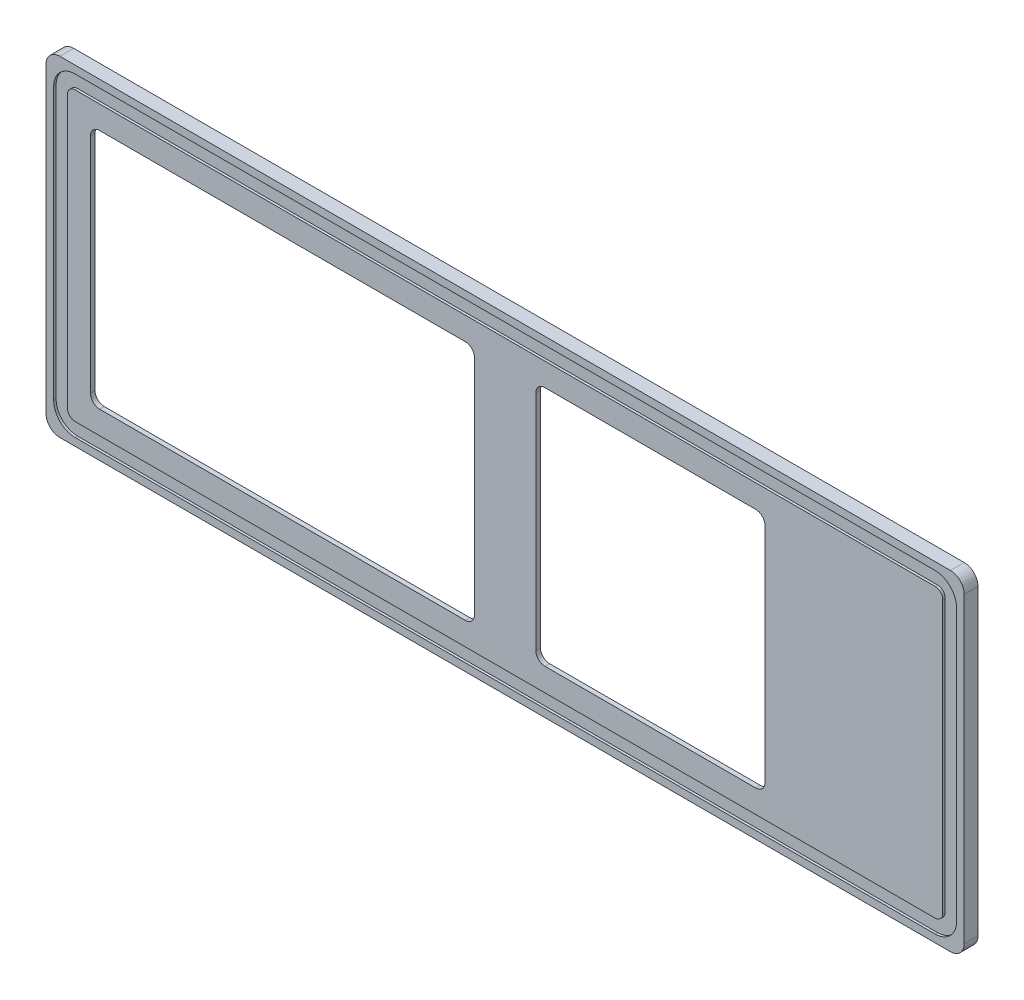
from build123d import *

# Parameters (mm, degrees)
BOSS_EXTRUDE1_DEPTH = 9
CUT_EXTRUDE1_DEPTH  = 1.6
CUT_EXTRUDE2_DEPTH  = 9
CUT_EXTRUDE4_DEPTH  = 6


with BuildPart() as part:
    # Sketch1 → Boss-Extrude1 (new body)
    with BuildSketch(Plane.XY):
        with BuildLine():
            Line((-290.5, 206.4), (290.5, 206.4))
            ThreePointArc((290.5, 206.4), (296.863961031, 203.763961031), (299.5, 197.4))
            Line((299.5, 197.4), (299.5, 0))
            ThreePointArc((299.5, 0), (296.863961031, -6.363961031), (290.5, -9))
            Line((290.5, -9), (-290.5, -9))
            ThreePointArc((-290.5, -9), (-296.863961031, -6.363961031), (-299.5, 0))
            Line((-299.5, 0), (-299.5, 197.4))
            ThreePointArc((-299.5, 197.4), (-296.863961031, 203.763961031), (-290.5, 206.4))
        make_face()
    extrude(amount=BOSS_EXTRUDE1_DEPTH)

    # Sketch4 → Cut-Extrude1 (cut)
    with BuildSketch(Plane.XY.offset(9)):
        with BuildLine():
            Line((-280.5, -4), (280.5, -4))
            ThreePointArc((280.5, -4), (290.399494937, 0.100505063), (294.5, 10))
            Line((294.5, 10), (294.5, 187.4))
            ThreePointArc((294.5, 187.4), (290.399494937, 197.299494937), (280.5, 201.4))
            Line((280.5, 201.4), (-280.5, 201.4))
            ThreePointArc((-280.5, 201.4), (-290.399494937, 197.299494937), (-294.5, 187.4))
            Line((-294.5, 187.4), (-294.5, 10))
            ThreePointArc((-294.5, 10), (-290.399494937, 0.100505063), (-280.5, -4))
        make_face()
        with BuildLine():
            Line((-280.5, 5), (280.5, 5))
            ThreePointArc((280.5, 5), (284.035533906, 6.464466094), (285.5, 10))
            Line((285.5, 10), (285.5, 187.4))
            ThreePointArc((285.5, 187.4), (284.035533906, 190.935533906), (280.5, 192.4))
            Line((280.5, 192.4), (-280.5, 192.4))
            ThreePointArc((-280.5, 192.4), (-284.035533906, 190.935533906), (-285.5, 187.4))
            Line((-285.5, 187.4), (-285.5, 10))
            ThreePointArc((-285.5, 10), (-284.035533906, 6.464466094), (-280.5, 5))
        make_face(mode=Mode.SUBTRACT)
    extrude(amount=-CUT_EXTRUDE1_DEPTH, mode=Mode.SUBTRACT)

    # Sketch5 → Cut-Extrude2 (cut)
    with BuildSketch(Plane.XY):
        with BuildLine():
            Line((-264.5, 177.4), (-26, 177.4))
            ThreePointArc((-26, 177.4), (-21.757359313, 175.642640687), (-20, 171.4))
            Line((-20, 171.4), (-20, 26))
            ThreePointArc((-20, 26), (-21.757359313, 21.757359313), (-26, 20))
            Line((-26, 20), (-264.5, 20))
            ThreePointArc((-264.5, 20), (-268.742640687, 21.757359313), (-270.5, 26))
            Line((-270.5, 26), (-270.5, 171.4))
            ThreePointArc((-270.5, 171.4), (-268.742640687, 175.642640687), (-264.5, 177.4))
        make_face()
        with BuildLine():
            Line((20, 171.4), (20, 26))
            ThreePointArc((20, 26), (21.757359313, 21.757359313), (26, 20))
            Line((26, 20), (163.5, 20))
            ThreePointArc((163.5, 20), (167.742640687, 21.757359313), (169.5, 26))
            Line((169.5, 26), (169.5, 171.4))
            ThreePointArc((169.5, 171.4), (167.742640687, 175.642640687), (163.5, 177.4))
            Line((163.5, 177.4), (26, 177.4))
            ThreePointArc((26, 177.4), (21.757359313, 175.642640687), (20, 171.4))
        make_face()
    extrude(amount=CUT_EXTRUDE2_DEPTH, mode=Mode.SUBTRACT)

    # Sketch7 → Cut-Extrude4 (cut)
    with BuildSketch(Plane(origin=(0, 0, 0), x_dir=(-1, 0, 0), z_dir=(0, 0, -1))):
        with BuildLine():
            Line((280.5, 26), (280.5, 171.4))
            ThreePointArc((280.5, 171.4), (275.813708499, 182.713708499), (264.5, 187.4))
            Line((264.5, 187.4), (26, 187.4))
            ThreePointArc((26, 187.4), (14.686291501, 182.713708499), (10, 171.4))
            Line((10, 171.4), (10, 26))
            ThreePointArc((10, 26), (14.686291501, 14.686291501), (26, 10))
            Line((26, 10), (264.5, 10))
            ThreePointArc((264.5, 10), (275.813708499, 14.686291501), (280.5, 26))
        make_face()
        with BuildLine():
            Line((-163.5, 10), (-26, 10))
            ThreePointArc((-26, 10), (-14.686291501, 14.686291501), (-10, 26))
            Line((-10, 26), (-10, 171.4))
            ThreePointArc((-10, 171.4), (-14.686291501, 182.713708499), (-26, 187.4))
            Line((-26, 187.4), (-163.5, 187.4))
            ThreePointArc((-163.5, 187.4), (-174.813708499, 182.713708499), (-179.5, 171.4))
            Line((-179.5, 171.4), (-179.5, 26))
            ThreePointArc((-179.5, 26), (-174.813708499, 14.686291501), (-163.5, 10))
        make_face()
    extrude(amount=-CUT_EXTRUDE4_DEPTH, mode=Mode.SUBTRACT)


solid = part.part
